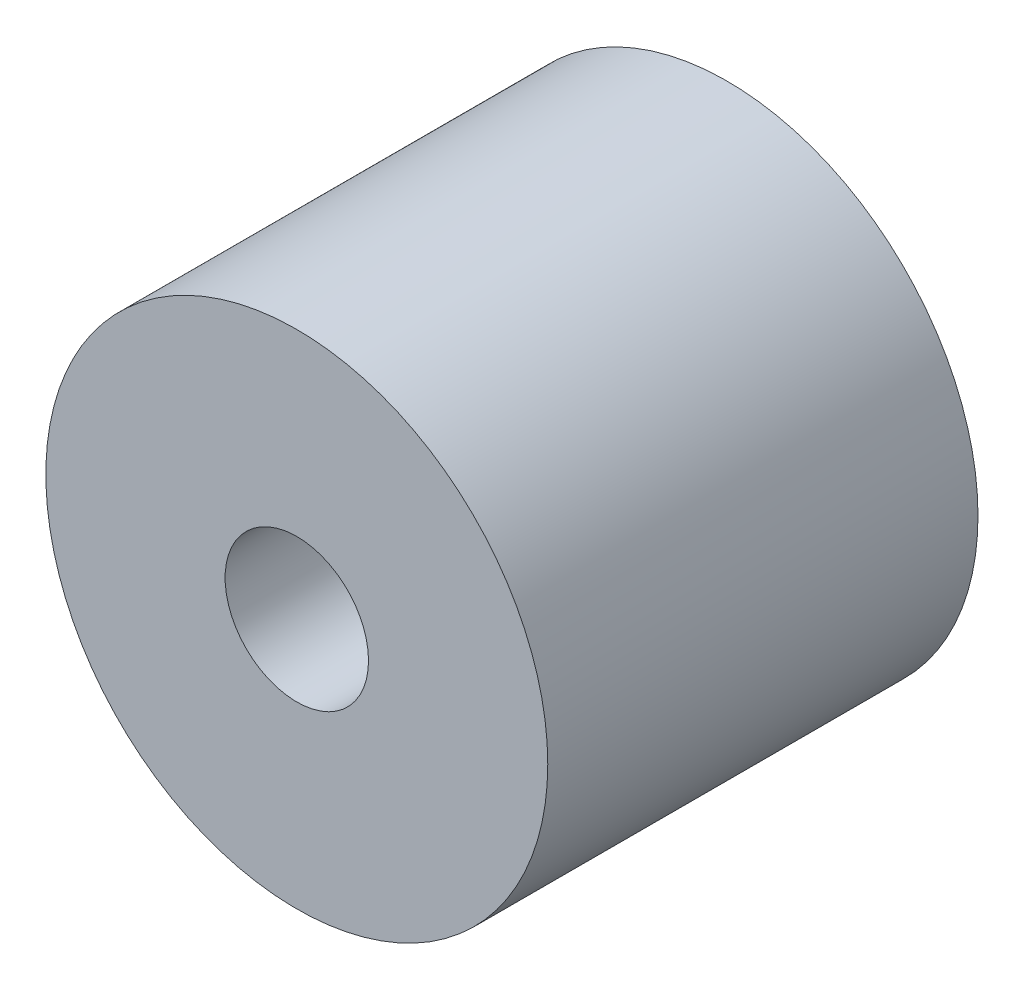
from build123d import *

# Parameters (mm, degrees)
CROQUIS1_R              = 17.5
CROQUIS1_R_2            = 5
SALIENTE_EXTRUIR1_DEPTH = 15


with BuildPart() as part:
    # Croquis1 → Saliente-Extruir1 (new body, symmetric)
    with BuildSketch(Plane.XY):
        Circle(CROQUIS1_R)
        Circle(CROQUIS1_R_2, mode=Mode.SUBTRACT)
    extrude(amount=SALIENTE_EXTRUIR1_DEPTH, both=True)


solid = part.part
